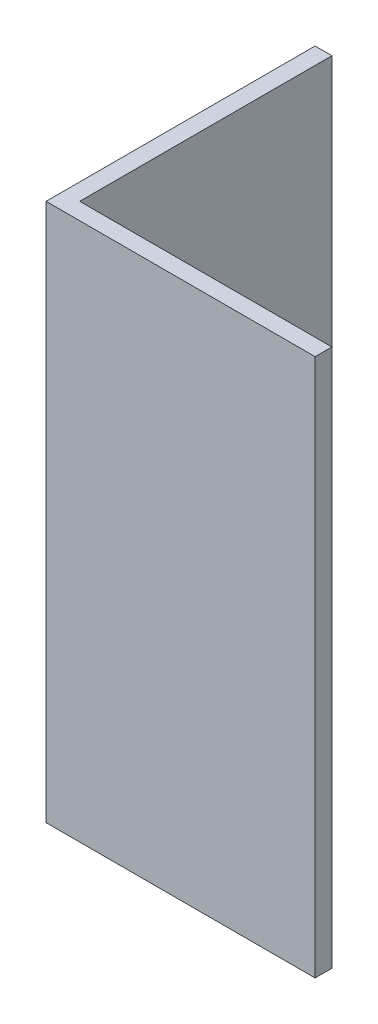
from build123d import *

# Parameters (mm, degrees)
BOSS_EXTRUDE1_DEPTH = 50.8


with BuildPart() as part:
    # Sketch1 → Boss-Extrude1 (new body)
    with BuildSketch(Plane(origin=(0, 0, 0), x_dir=(1, 0, 0), z_dir=(0, 1, 0))):
        Polygon((0, 0), (0, 25.4), (1.5875, 25.4), (1.5875, 1.5875), (25.4, 1.5875), (25.4, 0), align=None)
    extrude(amount=BOSS_EXTRUDE1_DEPTH)


solid = part.part
